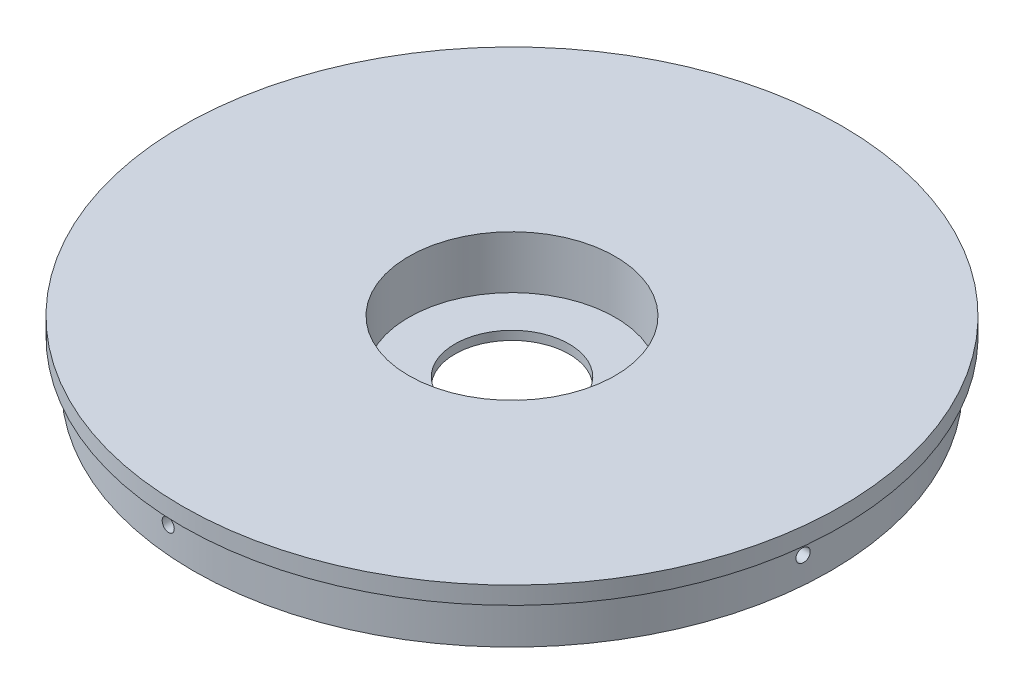
from build123d import *

# Parameters (mm, degrees)
SZKIC4_R                    = 75
DODANIE_WYCI_GNI_CIE2_DEPTH = 14
SZKIC5_R                    = 23.5
WYTNIJ_WYCI_GNI_CIE3_DEPTH  = 12
SZKIC6_R                    = 13
WYTNIJ_WYCI_GNI_CIE4_DEPTH  = 12
SZKIC7_R                    = 75
SZKIC7_R_2                  = 72.5
WYTNIJ_WYCI_GNI_CIE5_DEPTH  = 10
SZKIC8_R                    = 1.5
WYTNIJ_WYCI_GNI_CIE6_DEPTH  = 6
SZKIC10_R                   = 1.5
WYTNIJ_WYCI_GNI_CIE7_DEPTH  = 6
SZYK_KO_OWY1_COUNT          = 4


with BuildPart() as part:
    # Szkic4 → Dodanie-wyciągnięcie2 (new body)
    with BuildSketch(Plane(origin=(0, 0, 0), x_dir=(1, 0, 0), z_dir=(0, 1, 0))):
        Circle(SZKIC4_R)
    extrude(amount=DODANIE_WYCI_GNI_CIE2_DEPTH)

    # Szkic5 → Wytnij-wyciągnięcie3 (cut)
    with BuildSketch(Plane(origin=(0, 14, 0), x_dir=(1, 0, 0), z_dir=(0, 1, 0))):
        Circle(SZKIC5_R)
    extrude(amount=-WYTNIJ_WYCI_GNI_CIE3_DEPTH, mode=Mode.SUBTRACT)

    # Szkic6 → Wytnij-wyciągnięcie4 (cut)
    with BuildSketch(Plane(origin=(0, 2, 0), x_dir=(1, 0, 0), z_dir=(0, 1, 0))):
        Circle(SZKIC6_R)
    extrude(amount=-WYTNIJ_WYCI_GNI_CIE4_DEPTH, mode=Mode.SUBTRACT)

    # Szkic7 → Wytnij-wyciągnięcie5 (cut)
    with BuildSketch(Plane.XZ):
        Circle(SZKIC7_R)
        Circle(SZKIC7_R_2, mode=Mode.SUBTRACT)
    extrude(amount=-WYTNIJ_WYCI_GNI_CIE5_DEPTH, mode=Mode.SUBTRACT)

    # Szkic8 → Wytnij-wyciągnięcie6 (cut)
    with BuildSketch(Plane(origin=(0, 0, 0), x_dir=(-1, 0, 0), z_dir=(0, -1, 0))):
        with Locations((23.060270904, -19.500356556)):
            Circle(SZKIC8_R)
        with Locations((-28.863517887, 24.407731054)):
            Circle(SZKIC8_R)
    extrude(amount=-WYTNIJ_WYCI_GNI_CIE6_DEPTH, mode=Mode.SUBTRACT)

    # Szkic10 → Wytnij-wyciągnięcie7 (cut)
    with BuildSketch(Plane(origin=(0, 0, 72.5), x_dir=(0, -1, 0), z_dir=(0, 0, -1))):
        with Locations((-6, 6)):
            Circle(SZKIC10_R)
    wytnij_wyci_gni_cie7 = extrude(amount=WYTNIJ_WYCI_GNI_CIE7_DEPTH, mode=Mode.SUBTRACT)

    # Szyk kołowy1: Wytnij-wyciągnięcie7 ×4 about axis
    szyk_ko_owy1_axis = Axis((0, 0, 0), (0, 1, 0))
    for i in range(1, SZYK_KO_OWY1_COUNT):
        add(wytnij_wyci_gni_cie7.rotate(szyk_ko_owy1_axis, i * 360 / SZYK_KO_OWY1_COUNT), mode=Mode.SUBTRACT)


solid = part.part
